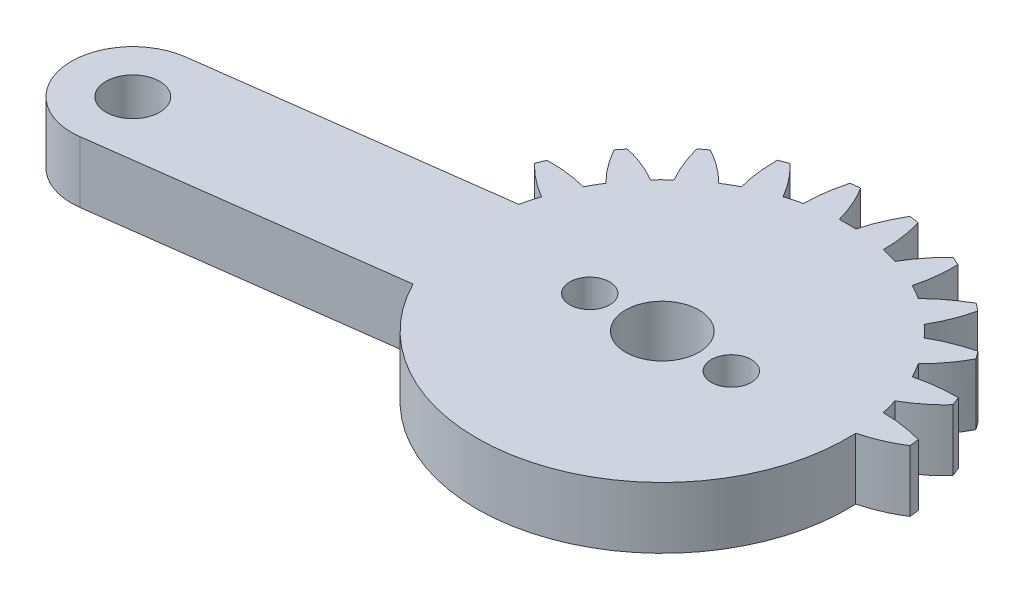
from build123d import *

# Parameters (mm, degrees)
CROQUIS1_R              = 2.3915
CROQUIS1_R_2            = 1.3
CROQUIS1_R_3            = 1.75
SALIENTE_EXTRUIR1_DEPTH = 4
SALIENTE_EXTRUIR2_DEPTH = 4
MATRIZC1_COUNT          = 2
MATRIZC1_ANGLE          = 15
MATRIZC2_COPY_1_DEPTH   = 4
MATRIZC2_COPY_2_DEPTH   = 4
MATRIZC3_COPY_1_DEPTH   = 4
MATRIZC3_COPY_2_DEPTH   = 4
MATRIZC3_COPY_3_DEPTH   = 4
MATRIZC4_COPY_1_DEPTH   = 4
MATRIZC4_COPY_2_DEPTH   = 4
MATRIZC4_COPY_3_DEPTH   = 4
MATRIZC4_COPY_4_DEPTH   = 4
MATRIZC5_COPY_1_DEPTH   = 4
MATRIZC5_COPY_2_DEPTH   = 4
MATRIZC5_COPY_3_DEPTH   = 4
MATRIZC5_COPY_4_DEPTH   = 4
MATRIZC5_COPY_5_DEPTH   = 4
MATRIZC6_COPY_1_DEPTH   = 4
MATRIZC6_COPY_2_DEPTH   = 4
MATRIZC6_COPY_3_DEPTH   = 4
MATRIZC6_COPY_4_DEPTH   = 4
MATRIZC6_COPY_5_DEPTH   = 4
MATRIZC6_COPY_6_DEPTH   = 4
MATRIZC7_COPY_1_DEPTH   = 4
MATRIZC7_COPY_2_DEPTH   = 4
MATRIZC7_COPY_3_DEPTH   = 4
MATRIZC7_COPY_4_DEPTH   = 4
MATRIZC7_COPY_5_DEPTH   = 4
MATRIZC7_COPY_6_DEPTH   = 4
MATRIZC7_COPY_7_DEPTH   = 4
MATRIZC8_COPY_1_DEPTH   = 4
MATRIZC8_COPY_2_DEPTH   = 4
MATRIZC8_COPY_3_DEPTH   = 4
MATRIZC8_COPY_4_DEPTH   = 4
MATRIZC8_COPY_5_DEPTH   = 4
MATRIZC8_COPY_6_DEPTH   = 4
MATRIZC8_COPY_7_DEPTH   = 4
MATRIZC8_COPY_8_DEPTH   = 4
MATRIZC9_COPY_1_DEPTH   = 4
MATRIZC9_COPY_2_DEPTH   = 4
MATRIZC9_COPY_3_DEPTH   = 4
MATRIZC9_COPY_4_DEPTH   = 4
MATRIZC9_COPY_5_DEPTH   = 4
MATRIZC9_COPY_6_DEPTH   = 4
MATRIZC9_COPY_7_DEPTH   = 4
MATRIZC9_COPY_8_DEPTH   = 4
MATRIZC9_COPY_9_DEPTH   = 4
MATRIZC10_COPY_1_DEPTH  = 4
MATRIZC10_COPY_2_DEPTH  = 4
MATRIZC10_COPY_3_DEPTH  = 4
MATRIZC10_COPY_4_DEPTH  = 4
MATRIZC10_COPY_5_DEPTH  = 4
MATRIZC10_COPY_6_DEPTH  = 4
MATRIZC10_COPY_7_DEPTH  = 4
MATRIZC10_COPY_8_DEPTH  = 4
MATRIZC10_COPY_9_DEPTH  = 4
MATRIZC10_COPY_10_DEPTH = 4


with BuildPart() as part:
    # Croquis1 → Saliente-Extruir1 (new body)
    with BuildSketch(Plane(origin=(0, 0, 0), x_dir=(1, 0, 0), z_dir=(0, 1, 0))):
        with BuildLine():
            Line((-10.778067685, -5.465198737), (-29.956952078, -7.999839876))
            ThreePointArc((-29.956952078, -7.999839876), (-34.453235787, -4.553267385), (-31.006663296, -0.056983677))
            Line((-31.006663296, -0.056983677), (-11.827778902, 2.477657462))
            ThreePointArc((-11.827778902, 2.477657462), (11.980330385, 1.583295338), (-10.778067685, -5.465198737))
        make_face()
        Circle(CROQUIS1_R, mode=Mode.SUBTRACT)
        with Locations((4.5, 0)):
            Circle(CROQUIS1_R_2, mode=Mode.SUBTRACT)
        with Locations((-4.494, -0.232301528)):
            Circle(CROQUIS1_R_2, mode=Mode.SUBTRACT)
        with Locations((-30.481807687, -4.028411777)):
            Circle(CROQUIS1_R_3, mode=Mode.SUBTRACT)
    extrude(amount=SALIENTE_EXTRUIR1_DEPTH)

    # Croquis2 → Saliente-Extruir2 (add)
    with BuildSketch(Plane(origin=(0, 0, 0), x_dir=(1, 0, 0), z_dir=(0, 1, 0))):
        with BuildLine():
            Line((-13.395904035, 5.876359313), (-13.644464088, 5.304001121))
            add(Edge.make_bspline(
                [(-11.519571955, 3.651657462), (-12.572280463, 4.239350994), (-13.644464088, 5.304001121)],
                knots=[0, 0, 0, 0.551059003, 0.551059003, 0.551059003], degree=2))
            add(Edge.make_bspline(
                [(-11.519571955, 3.651657462), (-11.202300794, 4.649704038), (-10.724126138, 5.570301502)],
                knots=[0, 0, 0, 0.773723424, 0.773723424, 0.773723424], degree=2))
            add(Edge.make_bspline(
                [(-10.724126138, 5.570301502), (-12.067942215, 5.934177007), (-13.395904035, 5.876359313)],
                knots=[0, 0, 0, 0.450010826, 0.450010826, 0.450010826], degree=2))
        make_face()
    saliente_extruir2 = extrude(amount=SALIENTE_EXTRUIR2_DEPTH)

    # MatrizC1: Saliente-Extruir2 ×2 about axis
    matrizc1_axis = Axis((0, 0, 0), (0, -1, 0))
    for i in range(1, MATRIZC1_COUNT):
        add(saliente_extruir2.rotate(matrizc1_axis, i * MATRIZC1_ANGLE / (MATRIZC1_COUNT - 1)))

    # MatrizC2 copy 1 sketch → MatrizC2 copy 1 (add)
    with BuildSketch(Plane(origin=(0, 0, 0), x_dir=(0.866025404, 0, 0.5), z_dir=(0, 1, 0))):
        with BuildLine():
            Line((-13.395904035, 5.876359313), (-13.644464088, 5.304001121))
            add(Edge.make_bspline(
                [(-11.519571955, 3.651657462), (-12.572280463, 4.239350994), (-13.644464088, 5.304001121)],
                knots=[0, 0, 0, 0.551059003, 0.551059003, 0.551059003], degree=2))
            add(Edge.make_bspline(
                [(-11.519571955, 3.651657462), (-11.202300794, 4.649704038), (-10.724126138, 5.570301502)],
                knots=[0, 0, 0, 0.773723424, 0.773723424, 0.773723424], degree=2))
            add(Edge.make_bspline(
                [(-10.724126138, 5.570301502), (-12.067942215, 5.934177007), (-13.395904035, 5.876359313)],
                knots=[0, 0, 0, 0.450010826, 0.450010826, 0.450010826], degree=2))
        make_face()
    extrude(amount=MATRIZC2_COPY_1_DEPTH)

    # MatrizC2 copy 2 sketch → MatrizC2 copy 2 (add)
    with BuildSketch(Plane(origin=(0, 0, 0), x_dir=(0.965925826, 0, 0.258819045), z_dir=(0, 1, 0))):
        with BuildLine():
            Line((-13.395904035, 5.876359313), (-13.644464088, 5.304001121))
            add(Edge.make_bspline(
                [(-11.519571955, 3.651657462), (-12.572280463, 4.239350994), (-13.644464088, 5.304001121)],
                knots=[0, 0, 0, 0.551059003, 0.551059003, 0.551059003], degree=2))
            add(Edge.make_bspline(
                [(-11.519571955, 3.651657462), (-11.202300794, 4.649704038), (-10.724126138, 5.570301502)],
                knots=[0, 0, 0, 0.773723424, 0.773723424, 0.773723424], degree=2))
            add(Edge.make_bspline(
                [(-10.724126138, 5.570301502), (-12.067942215, 5.934177007), (-13.395904035, 5.876359313)],
                knots=[0, 0, 0, 0.450010826, 0.450010826, 0.450010826], degree=2))
        make_face()
    extrude(amount=MATRIZC2_COPY_2_DEPTH)

    # MatrizC3 copy 1 sketch → MatrizC3 copy 1 (add)
    with BuildSketch(Plane(origin=(0, 0, 0), x_dir=(0.707106781, 0, 0.707106781), z_dir=(0, 1, 0))):
        with BuildLine():
            Line((-13.395904035, 5.876359313), (-13.644464088, 5.304001121))
            add(Edge.make_bspline(
                [(-11.519571955, 3.651657462), (-12.572280463, 4.239350994), (-13.644464088, 5.304001121)],
                knots=[0, 0, 0, 0.551059003, 0.551059003, 0.551059003], degree=2))
            add(Edge.make_bspline(
                [(-11.519571955, 3.651657462), (-11.202300794, 4.649704038), (-10.724126138, 5.570301502)],
                knots=[0, 0, 0, 0.773723424, 0.773723424, 0.773723424], degree=2))
            add(Edge.make_bspline(
                [(-10.724126138, 5.570301502), (-12.067942215, 5.934177007), (-13.395904035, 5.876359313)],
                knots=[0, 0, 0, 0.450010826, 0.450010826, 0.450010826], degree=2))
        make_face()
    extrude(amount=MATRIZC3_COPY_1_DEPTH)

    # MatrizC3 copy 2 sketch → MatrizC3 copy 2 (add)
    with BuildSketch(Plane(origin=(0, 0, 0), x_dir=(0.866025404, 0, 0.5), z_dir=(0, 1, 0))):
        with BuildLine():
            Line((-13.395904035, 5.876359313), (-13.644464088, 5.304001121))
            add(Edge.make_bspline(
                [(-11.519571955, 3.651657462), (-12.572280463, 4.239350994), (-13.644464088, 5.304001121)],
                knots=[0, 0, 0, 0.551059003, 0.551059003, 0.551059003], degree=2))
            add(Edge.make_bspline(
                [(-11.519571955, 3.651657462), (-11.202300794, 4.649704038), (-10.724126138, 5.570301502)],
                knots=[0, 0, 0, 0.773723424, 0.773723424, 0.773723424], degree=2))
            add(Edge.make_bspline(
                [(-10.724126138, 5.570301502), (-12.067942215, 5.934177007), (-13.395904035, 5.876359313)],
                knots=[0, 0, 0, 0.450010826, 0.450010826, 0.450010826], degree=2))
        make_face()
    extrude(amount=MATRIZC3_COPY_2_DEPTH)

    # MatrizC3 copy 3 sketch → MatrizC3 copy 3 (add)
    with BuildSketch(Plane(origin=(0, 0, 0), x_dir=(0.965925826, 0, 0.258819045), z_dir=(0, 1, 0))):
        with BuildLine():
            Line((-13.395904035, 5.876359313), (-13.644464088, 5.304001121))
            add(Edge.make_bspline(
                [(-11.519571955, 3.651657462), (-12.572280463, 4.239350994), (-13.644464088, 5.304001121)],
                knots=[0, 0, 0, 0.551059003, 0.551059003, 0.551059003], degree=2))
            add(Edge.make_bspline(
                [(-11.519571955, 3.651657462), (-11.202300794, 4.649704038), (-10.724126138, 5.570301502)],
                knots=[0, 0, 0, 0.773723424, 0.773723424, 0.773723424], degree=2))
            add(Edge.make_bspline(
                [(-10.724126138, 5.570301502), (-12.067942215, 5.934177007), (-13.395904035, 5.876359313)],
                knots=[0, 0, 0, 0.450010826, 0.450010826, 0.450010826], degree=2))
        make_face()
    extrude(amount=MATRIZC3_COPY_3_DEPTH)

    # MatrizC4 copy 1 sketch → MatrizC4 copy 1 (add)
    with BuildSketch(Plane(origin=(0, 0, 0), x_dir=(0.5, 0, 0.866025404), z_dir=(0, 1, 0))):
        with BuildLine():
            Line((-13.395904035, 5.876359313), (-13.644464088, 5.304001121))
            add(Edge.make_bspline(
                [(-11.519571955, 3.651657462), (-12.572280463, 4.239350994), (-13.644464088, 5.304001121)],
                knots=[0, 0, 0, 0.551059003, 0.551059003, 0.551059003], degree=2))
            add(Edge.make_bspline(
                [(-11.519571955, 3.651657462), (-11.202300794, 4.649704038), (-10.724126138, 5.570301502)],
                knots=[0, 0, 0, 0.773723424, 0.773723424, 0.773723424], degree=2))
            add(Edge.make_bspline(
                [(-10.724126138, 5.570301502), (-12.067942215, 5.934177007), (-13.395904035, 5.876359313)],
                knots=[0, 0, 0, 0.450010826, 0.450010826, 0.450010826], degree=2))
        make_face()
    extrude(amount=MATRIZC4_COPY_1_DEPTH)

    # MatrizC4 copy 2 sketch → MatrizC4 copy 2 (add)
    with BuildSketch(Plane(origin=(0, 0, 0), x_dir=(0.707106781, 0, 0.707106781), z_dir=(0, 1, 0))):
        with BuildLine():
            Line((-13.395904035, 5.876359313), (-13.644464088, 5.304001121))
            add(Edge.make_bspline(
                [(-11.519571955, 3.651657462), (-12.572280463, 4.239350994), (-13.644464088, 5.304001121)],
                knots=[0, 0, 0, 0.551059003, 0.551059003, 0.551059003], degree=2))
            add(Edge.make_bspline(
                [(-11.519571955, 3.651657462), (-11.202300794, 4.649704038), (-10.724126138, 5.570301502)],
                knots=[0, 0, 0, 0.773723424, 0.773723424, 0.773723424], degree=2))
            add(Edge.make_bspline(
                [(-10.724126138, 5.570301502), (-12.067942215, 5.934177007), (-13.395904035, 5.876359313)],
                knots=[0, 0, 0, 0.450010826, 0.450010826, 0.450010826], degree=2))
        make_face()
    extrude(amount=MATRIZC4_COPY_2_DEPTH)

    # MatrizC4 copy 3 sketch → MatrizC4 copy 3 (add)
    with BuildSketch(Plane(origin=(0, 0, 0), x_dir=(0.866025404, 0, 0.5), z_dir=(0, 1, 0))):
        with BuildLine():
            Line((-13.395904035, 5.876359313), (-13.644464088, 5.304001121))
            add(Edge.make_bspline(
                [(-11.519571955, 3.651657462), (-12.572280463, 4.239350994), (-13.644464088, 5.304001121)],
                knots=[0, 0, 0, 0.551059003, 0.551059003, 0.551059003], degree=2))
            add(Edge.make_bspline(
                [(-11.519571955, 3.651657462), (-11.202300794, 4.649704038), (-10.724126138, 5.570301502)],
                knots=[0, 0, 0, 0.773723424, 0.773723424, 0.773723424], degree=2))
            add(Edge.make_bspline(
                [(-10.724126138, 5.570301502), (-12.067942215, 5.934177007), (-13.395904035, 5.876359313)],
                knots=[0, 0, 0, 0.450010826, 0.450010826, 0.450010826], degree=2))
        make_face()
    extrude(amount=MATRIZC4_COPY_3_DEPTH)

    # MatrizC4 copy 4 sketch → MatrizC4 copy 4 (add)
    with BuildSketch(Plane(origin=(0, 0, 0), x_dir=(0.965925826, 0, 0.258819045), z_dir=(0, 1, 0))):
        with BuildLine():
            Line((-13.395904035, 5.876359313), (-13.644464088, 5.304001121))
            add(Edge.make_bspline(
                [(-11.519571955, 3.651657462), (-12.572280463, 4.239350994), (-13.644464088, 5.304001121)],
                knots=[0, 0, 0, 0.551059003, 0.551059003, 0.551059003], degree=2))
            add(Edge.make_bspline(
                [(-11.519571955, 3.651657462), (-11.202300794, 4.649704038), (-10.724126138, 5.570301502)],
                knots=[0, 0, 0, 0.773723424, 0.773723424, 0.773723424], degree=2))
            add(Edge.make_bspline(
                [(-10.724126138, 5.570301502), (-12.067942215, 5.934177007), (-13.395904035, 5.876359313)],
                knots=[0, 0, 0, 0.450010826, 0.450010826, 0.450010826], degree=2))
        make_face()
    extrude(amount=MATRIZC4_COPY_4_DEPTH)

    # MatrizC5 copy 1 sketch → MatrizC5 copy 1 (add)
    with BuildSketch(Plane(origin=(0, 0, 0), x_dir=(0.258819045, 0, 0.965925826), z_dir=(0, 1, 0))):
        with BuildLine():
            Line((-13.395904035, 5.876359313), (-13.644464088, 5.304001121))
            add(Edge.make_bspline(
                [(-11.519571955, 3.651657462), (-12.572280463, 4.239350994), (-13.644464088, 5.304001121)],
                knots=[0, 0, 0, 0.551059003, 0.551059003, 0.551059003], degree=2))
            add(Edge.make_bspline(
                [(-11.519571955, 3.651657462), (-11.202300794, 4.649704038), (-10.724126138, 5.570301502)],
                knots=[0, 0, 0, 0.773723424, 0.773723424, 0.773723424], degree=2))
            add(Edge.make_bspline(
                [(-10.724126138, 5.570301502), (-12.067942215, 5.934177007), (-13.395904035, 5.876359313)],
                knots=[0, 0, 0, 0.450010826, 0.450010826, 0.450010826], degree=2))
        make_face()
    extrude(amount=MATRIZC5_COPY_1_DEPTH)

    # MatrizC5 copy 2 sketch → MatrizC5 copy 2 (add)
    with BuildSketch(Plane(origin=(0, 0, 0), x_dir=(0.5, 0, 0.866025404), z_dir=(0, 1, 0))):
        with BuildLine():
            Line((-13.395904035, 5.876359313), (-13.644464088, 5.304001121))
            add(Edge.make_bspline(
                [(-11.519571955, 3.651657462), (-12.572280463, 4.239350994), (-13.644464088, 5.304001121)],
                knots=[0, 0, 0, 0.551059003, 0.551059003, 0.551059003], degree=2))
            add(Edge.make_bspline(
                [(-11.519571955, 3.651657462), (-11.202300794, 4.649704038), (-10.724126138, 5.570301502)],
                knots=[0, 0, 0, 0.773723424, 0.773723424, 0.773723424], degree=2))
            add(Edge.make_bspline(
                [(-10.724126138, 5.570301502), (-12.067942215, 5.934177007), (-13.395904035, 5.876359313)],
                knots=[0, 0, 0, 0.450010826, 0.450010826, 0.450010826], degree=2))
        make_face()
    extrude(amount=MATRIZC5_COPY_2_DEPTH)

    # MatrizC5 copy 3 sketch → MatrizC5 copy 3 (add)
    with BuildSketch(Plane(origin=(0, 0, 0), x_dir=(0.707106781, 0, 0.707106781), z_dir=(0, 1, 0))):
        with BuildLine():
            Line((-13.395904035, 5.876359313), (-13.644464088, 5.304001121))
            add(Edge.make_bspline(
                [(-11.519571955, 3.651657462), (-12.572280463, 4.239350994), (-13.644464088, 5.304001121)],
                knots=[0, 0, 0, 0.551059003, 0.551059003, 0.551059003], degree=2))
            add(Edge.make_bspline(
                [(-11.519571955, 3.651657462), (-11.202300794, 4.649704038), (-10.724126138, 5.570301502)],
                knots=[0, 0, 0, 0.773723424, 0.773723424, 0.773723424], degree=2))
            add(Edge.make_bspline(
                [(-10.724126138, 5.570301502), (-12.067942215, 5.934177007), (-13.395904035, 5.876359313)],
                knots=[0, 0, 0, 0.450010826, 0.450010826, 0.450010826], degree=2))
        make_face()
    extrude(amount=MATRIZC5_COPY_3_DEPTH)

    # MatrizC5 copy 4 sketch → MatrizC5 copy 4 (add)
    with BuildSketch(Plane(origin=(0, 0, 0), x_dir=(0.866025404, 0, 0.5), z_dir=(0, 1, 0))):
        with BuildLine():
            Line((-13.395904035, 5.876359313), (-13.644464088, 5.304001121))
            add(Edge.make_bspline(
                [(-11.519571955, 3.651657462), (-12.572280463, 4.239350994), (-13.644464088, 5.304001121)],
                knots=[0, 0, 0, 0.551059003, 0.551059003, 0.551059003], degree=2))
            add(Edge.make_bspline(
                [(-11.519571955, 3.651657462), (-11.202300794, 4.649704038), (-10.724126138, 5.570301502)],
                knots=[0, 0, 0, 0.773723424, 0.773723424, 0.773723424], degree=2))
            add(Edge.make_bspline(
                [(-10.724126138, 5.570301502), (-12.067942215, 5.934177007), (-13.395904035, 5.876359313)],
                knots=[0, 0, 0, 0.450010826, 0.450010826, 0.450010826], degree=2))
        make_face()
    extrude(amount=MATRIZC5_COPY_4_DEPTH)

    # MatrizC5 copy 5 sketch → MatrizC5 copy 5 (add)
    with BuildSketch(Plane(origin=(0, 0, 0), x_dir=(0.965925826, 0, 0.258819045), z_dir=(0, 1, 0))):
        with BuildLine():
            Line((-13.395904035, 5.876359313), (-13.644464088, 5.304001121))
            add(Edge.make_bspline(
                [(-11.519571955, 3.651657462), (-12.572280463, 4.239350994), (-13.644464088, 5.304001121)],
                knots=[0, 0, 0, 0.551059003, 0.551059003, 0.551059003], degree=2))
            add(Edge.make_bspline(
                [(-11.519571955, 3.651657462), (-11.202300794, 4.649704038), (-10.724126138, 5.570301502)],
                knots=[0, 0, 0, 0.773723424, 0.773723424, 0.773723424], degree=2))
            add(Edge.make_bspline(
                [(-10.724126138, 5.570301502), (-12.067942215, 5.934177007), (-13.395904035, 5.876359313)],
                knots=[0, 0, 0, 0.450010826, 0.450010826, 0.450010826], degree=2))
        make_face()
    extrude(amount=MATRIZC5_COPY_5_DEPTH)

    # MatrizC6 copy 1 sketch → MatrizC6 copy 1 (add)
    with BuildSketch(Plane.ZX):
        with BuildLine():
            Line((-13.395904035, 5.876359313), (-13.644464088, 5.304001121))
            add(Edge.make_bspline(
                [(-11.519571955, 3.651657462), (-12.572280463, 4.239350994), (-13.644464088, 5.304001121)],
                knots=[0, 0, 0, 0.551059003, 0.551059003, 0.551059003], degree=2))
            add(Edge.make_bspline(
                [(-11.519571955, 3.651657462), (-11.202300794, 4.649704038), (-10.724126138, 5.570301502)],
                knots=[0, 0, 0, 0.773723424, 0.773723424, 0.773723424], degree=2))
            add(Edge.make_bspline(
                [(-10.724126138, 5.570301502), (-12.067942215, 5.934177007), (-13.395904035, 5.876359313)],
                knots=[0, 0, 0, 0.450010826, 0.450010826, 0.450010826], degree=2))
        make_face()
    extrude(amount=MATRIZC6_COPY_1_DEPTH)

    # MatrizC6 copy 2 sketch → MatrizC6 copy 2 (add)
    with BuildSketch(Plane(origin=(0, 0, 0), x_dir=(0.258819045, 0, 0.965925826), z_dir=(0, 1, 0))):
        with BuildLine():
            Line((-13.395904035, 5.876359313), (-13.644464088, 5.304001121))
            add(Edge.make_bspline(
                [(-11.519571955, 3.651657462), (-12.572280463, 4.239350994), (-13.644464088, 5.304001121)],
                knots=[0, 0, 0, 0.551059003, 0.551059003, 0.551059003], degree=2))
            add(Edge.make_bspline(
                [(-11.519571955, 3.651657462), (-11.202300794, 4.649704038), (-10.724126138, 5.570301502)],
                knots=[0, 0, 0, 0.773723424, 0.773723424, 0.773723424], degree=2))
            add(Edge.make_bspline(
                [(-10.724126138, 5.570301502), (-12.067942215, 5.934177007), (-13.395904035, 5.876359313)],
                knots=[0, 0, 0, 0.450010826, 0.450010826, 0.450010826], degree=2))
        make_face()
    extrude(amount=MATRIZC6_COPY_2_DEPTH)

    # MatrizC6 copy 3 sketch → MatrizC6 copy 3 (add)
    with BuildSketch(Plane(origin=(0, 0, 0), x_dir=(0.5, 0, 0.866025404), z_dir=(0, 1, 0))):
        with BuildLine():
            Line((-13.395904035, 5.876359313), (-13.644464088, 5.304001121))
            add(Edge.make_bspline(
                [(-11.519571955, 3.651657462), (-12.572280463, 4.239350994), (-13.644464088, 5.304001121)],
                knots=[0, 0, 0, 0.551059003, 0.551059003, 0.551059003], degree=2))
            add(Edge.make_bspline(
                [(-11.519571955, 3.651657462), (-11.202300794, 4.649704038), (-10.724126138, 5.570301502)],
                knots=[0, 0, 0, 0.773723424, 0.773723424, 0.773723424], degree=2))
            add(Edge.make_bspline(
                [(-10.724126138, 5.570301502), (-12.067942215, 5.934177007), (-13.395904035, 5.876359313)],
                knots=[0, 0, 0, 0.450010826, 0.450010826, 0.450010826], degree=2))
        make_face()
    extrude(amount=MATRIZC6_COPY_3_DEPTH)

    # MatrizC6 copy 4 sketch → MatrizC6 copy 4 (add)
    with BuildSketch(Plane(origin=(0, 0, 0), x_dir=(0.707106781, 0, 0.707106781), z_dir=(0, 1, 0))):
        with BuildLine():
            Line((-13.395904035, 5.876359313), (-13.644464088, 5.304001121))
            add(Edge.make_bspline(
                [(-11.519571955, 3.651657462), (-12.572280463, 4.239350994), (-13.644464088, 5.304001121)],
                knots=[0, 0, 0, 0.551059003, 0.551059003, 0.551059003], degree=2))
            add(Edge.make_bspline(
                [(-11.519571955, 3.651657462), (-11.202300794, 4.649704038), (-10.724126138, 5.570301502)],
                knots=[0, 0, 0, 0.773723424, 0.773723424, 0.773723424], degree=2))
            add(Edge.make_bspline(
                [(-10.724126138, 5.570301502), (-12.067942215, 5.934177007), (-13.395904035, 5.876359313)],
                knots=[0, 0, 0, 0.450010826, 0.450010826, 0.450010826], degree=2))
        make_face()
    extrude(amount=MATRIZC6_COPY_4_DEPTH)

    # MatrizC6 copy 5 sketch → MatrizC6 copy 5 (add)
    with BuildSketch(Plane(origin=(0, 0, 0), x_dir=(0.866025404, 0, 0.5), z_dir=(0, 1, 0))):
        with BuildLine():
            Line((-13.395904035, 5.876359313), (-13.644464088, 5.304001121))
            add(Edge.make_bspline(
                [(-11.519571955, 3.651657462), (-12.572280463, 4.239350994), (-13.644464088, 5.304001121)],
                knots=[0, 0, 0, 0.551059003, 0.551059003, 0.551059003], degree=2))
            add(Edge.make_bspline(
                [(-11.519571955, 3.651657462), (-11.202300794, 4.649704038), (-10.724126138, 5.570301502)],
                knots=[0, 0, 0, 0.773723424, 0.773723424, 0.773723424], degree=2))
            add(Edge.make_bspline(
                [(-10.724126138, 5.570301502), (-12.067942215, 5.934177007), (-13.395904035, 5.876359313)],
                knots=[0, 0, 0, 0.450010826, 0.450010826, 0.450010826], degree=2))
        make_face()
    extrude(amount=MATRIZC6_COPY_5_DEPTH)

    # MatrizC6 copy 6 sketch → MatrizC6 copy 6 (add)
    with BuildSketch(Plane(origin=(0, 0, 0), x_dir=(0.965925826, 0, 0.258819045), z_dir=(0, 1, 0))):
        with BuildLine():
            Line((-13.395904035, 5.876359313), (-13.644464088, 5.304001121))
            add(Edge.make_bspline(
                [(-11.519571955, 3.651657462), (-12.572280463, 4.239350994), (-13.644464088, 5.304001121)],
                knots=[0, 0, 0, 0.551059003, 0.551059003, 0.551059003], degree=2))
            add(Edge.make_bspline(
                [(-11.519571955, 3.651657462), (-11.202300794, 4.649704038), (-10.724126138, 5.570301502)],
                knots=[0, 0, 0, 0.773723424, 0.773723424, 0.773723424], degree=2))
            add(Edge.make_bspline(
                [(-10.724126138, 5.570301502), (-12.067942215, 5.934177007), (-13.395904035, 5.876359313)],
                knots=[0, 0, 0, 0.450010826, 0.450010826, 0.450010826], degree=2))
        make_face()
    extrude(amount=MATRIZC6_COPY_6_DEPTH)

    # MatrizC7 copy 1 sketch → MatrizC7 copy 1 (add)
    with BuildSketch(Plane(origin=(0, 0, 0), x_dir=(-0.258819045, 0, 0.965925826), z_dir=(0, 1, 0))):
        with BuildLine():
            Line((-13.395904035, 5.876359313), (-13.644464088, 5.304001121))
            add(Edge.make_bspline(
                [(-11.519571955, 3.651657462), (-12.572280463, 4.239350994), (-13.644464088, 5.304001121)],
                knots=[0, 0, 0, 0.551059003, 0.551059003, 0.551059003], degree=2))
            add(Edge.make_bspline(
                [(-11.519571955, 3.651657462), (-11.202300794, 4.649704038), (-10.724126138, 5.570301502)],
                knots=[0, 0, 0, 0.773723424, 0.773723424, 0.773723424], degree=2))
            add(Edge.make_bspline(
                [(-10.724126138, 5.570301502), (-12.067942215, 5.934177007), (-13.395904035, 5.876359313)],
                knots=[0, 0, 0, 0.450010826, 0.450010826, 0.450010826], degree=2))
        make_face()
    extrude(amount=MATRIZC7_COPY_1_DEPTH)

    # MatrizC7 copy 2 sketch → MatrizC7 copy 2 (add)
    with BuildSketch(Plane.ZX):
        with BuildLine():
            Line((-13.395904035, 5.876359313), (-13.644464088, 5.304001121))
            add(Edge.make_bspline(
                [(-11.519571955, 3.651657462), (-12.572280463, 4.239350994), (-13.644464088, 5.304001121)],
                knots=[0, 0, 0, 0.551059003, 0.551059003, 0.551059003], degree=2))
            add(Edge.make_bspline(
                [(-11.519571955, 3.651657462), (-11.202300794, 4.649704038), (-10.724126138, 5.570301502)],
                knots=[0, 0, 0, 0.773723424, 0.773723424, 0.773723424], degree=2))
            add(Edge.make_bspline(
                [(-10.724126138, 5.570301502), (-12.067942215, 5.934177007), (-13.395904035, 5.876359313)],
                knots=[0, 0, 0, 0.450010826, 0.450010826, 0.450010826], degree=2))
        make_face()
    extrude(amount=MATRIZC7_COPY_2_DEPTH)

    # MatrizC7 copy 3 sketch → MatrizC7 copy 3 (add)
    with BuildSketch(Plane(origin=(0, 0, 0), x_dir=(0.258819045, 0, 0.965925826), z_dir=(0, 1, 0))):
        with BuildLine():
            Line((-13.395904035, 5.876359313), (-13.644464088, 5.304001121))
            add(Edge.make_bspline(
                [(-11.519571955, 3.651657462), (-12.572280463, 4.239350994), (-13.644464088, 5.304001121)],
                knots=[0, 0, 0, 0.551059003, 0.551059003, 0.551059003], degree=2))
            add(Edge.make_bspline(
                [(-11.519571955, 3.651657462), (-11.202300794, 4.649704038), (-10.724126138, 5.570301502)],
                knots=[0, 0, 0, 0.773723424, 0.773723424, 0.773723424], degree=2))
            add(Edge.make_bspline(
                [(-10.724126138, 5.570301502), (-12.067942215, 5.934177007), (-13.395904035, 5.876359313)],
                knots=[0, 0, 0, 0.450010826, 0.450010826, 0.450010826], degree=2))
        make_face()
    extrude(amount=MATRIZC7_COPY_3_DEPTH)

    # MatrizC7 copy 4 sketch → MatrizC7 copy 4 (add)
    with BuildSketch(Plane(origin=(0, 0, 0), x_dir=(0.5, 0, 0.866025404), z_dir=(0, 1, 0))):
        with BuildLine():
            Line((-13.395904035, 5.876359313), (-13.644464088, 5.304001121))
            add(Edge.make_bspline(
                [(-11.519571955, 3.651657462), (-12.572280463, 4.239350994), (-13.644464088, 5.304001121)],
                knots=[0, 0, 0, 0.551059003, 0.551059003, 0.551059003], degree=2))
            add(Edge.make_bspline(
                [(-11.519571955, 3.651657462), (-11.202300794, 4.649704038), (-10.724126138, 5.570301502)],
                knots=[0, 0, 0, 0.773723424, 0.773723424, 0.773723424], degree=2))
            add(Edge.make_bspline(
                [(-10.724126138, 5.570301502), (-12.067942215, 5.934177007), (-13.395904035, 5.876359313)],
                knots=[0, 0, 0, 0.450010826, 0.450010826, 0.450010826], degree=2))
        make_face()
    extrude(amount=MATRIZC7_COPY_4_DEPTH)

    # MatrizC7 copy 5 sketch → MatrizC7 copy 5 (add)
    with BuildSketch(Plane(origin=(0, 0, 0), x_dir=(0.707106781, 0, 0.707106781), z_dir=(0, 1, 0))):
        with BuildLine():
            Line((-13.395904035, 5.876359313), (-13.644464088, 5.304001121))
            add(Edge.make_bspline(
                [(-11.519571955, 3.651657462), (-12.572280463, 4.239350994), (-13.644464088, 5.304001121)],
                knots=[0, 0, 0, 0.551059003, 0.551059003, 0.551059003], degree=2))
            add(Edge.make_bspline(
                [(-11.519571955, 3.651657462), (-11.202300794, 4.649704038), (-10.724126138, 5.570301502)],
                knots=[0, 0, 0, 0.773723424, 0.773723424, 0.773723424], degree=2))
            add(Edge.make_bspline(
                [(-10.724126138, 5.570301502), (-12.067942215, 5.934177007), (-13.395904035, 5.876359313)],
                knots=[0, 0, 0, 0.450010826, 0.450010826, 0.450010826], degree=2))
        make_face()
    extrude(amount=MATRIZC7_COPY_5_DEPTH)

    # MatrizC7 copy 6 sketch → MatrizC7 copy 6 (add)
    with BuildSketch(Plane(origin=(0, 0, 0), x_dir=(0.866025404, 0, 0.5), z_dir=(0, 1, 0))):
        with BuildLine():
            Line((-13.395904035, 5.876359313), (-13.644464088, 5.304001121))
            add(Edge.make_bspline(
                [(-11.519571955, 3.651657462), (-12.572280463, 4.239350994), (-13.644464088, 5.304001121)],
                knots=[0, 0, 0, 0.551059003, 0.551059003, 0.551059003], degree=2))
            add(Edge.make_bspline(
                [(-11.519571955, 3.651657462), (-11.202300794, 4.649704038), (-10.724126138, 5.570301502)],
                knots=[0, 0, 0, 0.773723424, 0.773723424, 0.773723424], degree=2))
            add(Edge.make_bspline(
                [(-10.724126138, 5.570301502), (-12.067942215, 5.934177007), (-13.395904035, 5.876359313)],
                knots=[0, 0, 0, 0.450010826, 0.450010826, 0.450010826], degree=2))
        make_face()
    extrude(amount=MATRIZC7_COPY_6_DEPTH)

    # MatrizC7 copy 7 sketch → MatrizC7 copy 7 (add)
    with BuildSketch(Plane(origin=(0, 0, 0), x_dir=(0.965925826, 0, 0.258819045), z_dir=(0, 1, 0))):
        with BuildLine():
            Line((-13.395904035, 5.876359313), (-13.644464088, 5.304001121))
            add(Edge.make_bspline(
                [(-11.519571955, 3.651657462), (-12.572280463, 4.239350994), (-13.644464088, 5.304001121)],
                knots=[0, 0, 0, 0.551059003, 0.551059003, 0.551059003], degree=2))
            add(Edge.make_bspline(
                [(-11.519571955, 3.651657462), (-11.202300794, 4.649704038), (-10.724126138, 5.570301502)],
                knots=[0, 0, 0, 0.773723424, 0.773723424, 0.773723424], degree=2))
            add(Edge.make_bspline(
                [(-10.724126138, 5.570301502), (-12.067942215, 5.934177007), (-13.395904035, 5.876359313)],
                knots=[0, 0, 0, 0.450010826, 0.450010826, 0.450010826], degree=2))
        make_face()
    extrude(amount=MATRIZC7_COPY_7_DEPTH)

    # MatrizC8 copy 1 sketch → MatrizC8 copy 1 (add)
    with BuildSketch(Plane(origin=(0, 0, 0), x_dir=(-0.5, 0, 0.866025404), z_dir=(0, 1, 0))):
        with BuildLine():
            Line((-13.395904035, 5.876359313), (-13.644464088, 5.304001121))
            add(Edge.make_bspline(
                [(-11.519571955, 3.651657462), (-12.572280463, 4.239350994), (-13.644464088, 5.304001121)],
                knots=[0, 0, 0, 0.551059003, 0.551059003, 0.551059003], degree=2))
            add(Edge.make_bspline(
                [(-11.519571955, 3.651657462), (-11.202300794, 4.649704038), (-10.724126138, 5.570301502)],
                knots=[0, 0, 0, 0.773723424, 0.773723424, 0.773723424], degree=2))
            add(Edge.make_bspline(
                [(-10.724126138, 5.570301502), (-12.067942215, 5.934177007), (-13.395904035, 5.876359313)],
                knots=[0, 0, 0, 0.450010826, 0.450010826, 0.450010826], degree=2))
        make_face()
    extrude(amount=MATRIZC8_COPY_1_DEPTH)

    # MatrizC8 copy 2 sketch → MatrizC8 copy 2 (add)
    with BuildSketch(Plane(origin=(0, 0, 0), x_dir=(-0.258819045, 0, 0.965925826), z_dir=(0, 1, 0))):
        with BuildLine():
            Line((-13.395904035, 5.876359313), (-13.644464088, 5.304001121))
            add(Edge.make_bspline(
                [(-11.519571955, 3.651657462), (-12.572280463, 4.239350994), (-13.644464088, 5.304001121)],
                knots=[0, 0, 0, 0.551059003, 0.551059003, 0.551059003], degree=2))
            add(Edge.make_bspline(
                [(-11.519571955, 3.651657462), (-11.202300794, 4.649704038), (-10.724126138, 5.570301502)],
                knots=[0, 0, 0, 0.773723424, 0.773723424, 0.773723424], degree=2))
            add(Edge.make_bspline(
                [(-10.724126138, 5.570301502), (-12.067942215, 5.934177007), (-13.395904035, 5.876359313)],
                knots=[0, 0, 0, 0.450010826, 0.450010826, 0.450010826], degree=2))
        make_face()
    extrude(amount=MATRIZC8_COPY_2_DEPTH)

    # MatrizC8 copy 3 sketch → MatrizC8 copy 3 (add)
    with BuildSketch(Plane.ZX):
        with BuildLine():
            Line((-13.395904035, 5.876359313), (-13.644464088, 5.304001121))
            add(Edge.make_bspline(
                [(-11.519571955, 3.651657462), (-12.572280463, 4.239350994), (-13.644464088, 5.304001121)],
                knots=[0, 0, 0, 0.551059003, 0.551059003, 0.551059003], degree=2))
            add(Edge.make_bspline(
                [(-11.519571955, 3.651657462), (-11.202300794, 4.649704038), (-10.724126138, 5.570301502)],
                knots=[0, 0, 0, 0.773723424, 0.773723424, 0.773723424], degree=2))
            add(Edge.make_bspline(
                [(-10.724126138, 5.570301502), (-12.067942215, 5.934177007), (-13.395904035, 5.876359313)],
                knots=[0, 0, 0, 0.450010826, 0.450010826, 0.450010826], degree=2))
        make_face()
    extrude(amount=MATRIZC8_COPY_3_DEPTH)

    # MatrizC8 copy 4 sketch → MatrizC8 copy 4 (add)
    with BuildSketch(Plane(origin=(0, 0, 0), x_dir=(0.258819045, 0, 0.965925826), z_dir=(0, 1, 0))):
        with BuildLine():
            Line((-13.395904035, 5.876359313), (-13.644464088, 5.304001121))
            add(Edge.make_bspline(
                [(-11.519571955, 3.651657462), (-12.572280463, 4.239350994), (-13.644464088, 5.304001121)],
                knots=[0, 0, 0, 0.551059003, 0.551059003, 0.551059003], degree=2))
            add(Edge.make_bspline(
                [(-11.519571955, 3.651657462), (-11.202300794, 4.649704038), (-10.724126138, 5.570301502)],
                knots=[0, 0, 0, 0.773723424, 0.773723424, 0.773723424], degree=2))
            add(Edge.make_bspline(
                [(-10.724126138, 5.570301502), (-12.067942215, 5.934177007), (-13.395904035, 5.876359313)],
                knots=[0, 0, 0, 0.450010826, 0.450010826, 0.450010826], degree=2))
        make_face()
    extrude(amount=MATRIZC8_COPY_4_DEPTH)

    # MatrizC8 copy 5 sketch → MatrizC8 copy 5 (add)
    with BuildSketch(Plane(origin=(0, 0, 0), x_dir=(0.5, 0, 0.866025404), z_dir=(0, 1, 0))):
        with BuildLine():
            Line((-13.395904035, 5.876359313), (-13.644464088, 5.304001121))
            add(Edge.make_bspline(
                [(-11.519571955, 3.651657462), (-12.572280463, 4.239350994), (-13.644464088, 5.304001121)],
                knots=[0, 0, 0, 0.551059003, 0.551059003, 0.551059003], degree=2))
            add(Edge.make_bspline(
                [(-11.519571955, 3.651657462), (-11.202300794, 4.649704038), (-10.724126138, 5.570301502)],
                knots=[0, 0, 0, 0.773723424, 0.773723424, 0.773723424], degree=2))
            add(Edge.make_bspline(
                [(-10.724126138, 5.570301502), (-12.067942215, 5.934177007), (-13.395904035, 5.876359313)],
                knots=[0, 0, 0, 0.450010826, 0.450010826, 0.450010826], degree=2))
        make_face()
    extrude(amount=MATRIZC8_COPY_5_DEPTH)

    # MatrizC8 copy 6 sketch → MatrizC8 copy 6 (add)
    with BuildSketch(Plane(origin=(0, 0, 0), x_dir=(0.707106781, 0, 0.707106781), z_dir=(0, 1, 0))):
        with BuildLine():
            Line((-13.395904035, 5.876359313), (-13.644464088, 5.304001121))
            add(Edge.make_bspline(
                [(-11.519571955, 3.651657462), (-12.572280463, 4.239350994), (-13.644464088, 5.304001121)],
                knots=[0, 0, 0, 0.551059003, 0.551059003, 0.551059003], degree=2))
            add(Edge.make_bspline(
                [(-11.519571955, 3.651657462), (-11.202300794, 4.649704038), (-10.724126138, 5.570301502)],
                knots=[0, 0, 0, 0.773723424, 0.773723424, 0.773723424], degree=2))
            add(Edge.make_bspline(
                [(-10.724126138, 5.570301502), (-12.067942215, 5.934177007), (-13.395904035, 5.876359313)],
                knots=[0, 0, 0, 0.450010826, 0.450010826, 0.450010826], degree=2))
        make_face()
    extrude(amount=MATRIZC8_COPY_6_DEPTH)

    # MatrizC8 copy 7 sketch → MatrizC8 copy 7 (add)
    with BuildSketch(Plane(origin=(0, 0, 0), x_dir=(0.866025404, 0, 0.5), z_dir=(0, 1, 0))):
        with BuildLine():
            Line((-13.395904035, 5.876359313), (-13.644464088, 5.304001121))
            add(Edge.make_bspline(
                [(-11.519571955, 3.651657462), (-12.572280463, 4.239350994), (-13.644464088, 5.304001121)],
                knots=[0, 0, 0, 0.551059003, 0.551059003, 0.551059003], degree=2))
            add(Edge.make_bspline(
                [(-11.519571955, 3.651657462), (-11.202300794, 4.649704038), (-10.724126138, 5.570301502)],
                knots=[0, 0, 0, 0.773723424, 0.773723424, 0.773723424], degree=2))
            add(Edge.make_bspline(
                [(-10.724126138, 5.570301502), (-12.067942215, 5.934177007), (-13.395904035, 5.876359313)],
                knots=[0, 0, 0, 0.450010826, 0.450010826, 0.450010826], degree=2))
        make_face()
    extrude(amount=MATRIZC8_COPY_7_DEPTH)

    # MatrizC8 copy 8 sketch → MatrizC8 copy 8 (add)
    with BuildSketch(Plane(origin=(0, 0, 0), x_dir=(0.965925826, 0, 0.258819045), z_dir=(0, 1, 0))):
        with BuildLine():
            Line((-13.395904035, 5.876359313), (-13.644464088, 5.304001121))
            add(Edge.make_bspline(
                [(-11.519571955, 3.651657462), (-12.572280463, 4.239350994), (-13.644464088, 5.304001121)],
                knots=[0, 0, 0, 0.551059003, 0.551059003, 0.551059003], degree=2))
            add(Edge.make_bspline(
                [(-11.519571955, 3.651657462), (-11.202300794, 4.649704038), (-10.724126138, 5.570301502)],
                knots=[0, 0, 0, 0.773723424, 0.773723424, 0.773723424], degree=2))
            add(Edge.make_bspline(
                [(-10.724126138, 5.570301502), (-12.067942215, 5.934177007), (-13.395904035, 5.876359313)],
                knots=[0, 0, 0, 0.450010826, 0.450010826, 0.450010826], degree=2))
        make_face()
    extrude(amount=MATRIZC8_COPY_8_DEPTH)

    # MatrizC9 copy 1 sketch → MatrizC9 copy 1 (add)
    with BuildSketch(Plane(origin=(0, 0, 0), x_dir=(-0.707106781, 0, 0.707106781), z_dir=(0, 1, 0))):
        with BuildLine():
            Line((-13.395904035, 5.876359313), (-13.644464088, 5.304001121))
            add(Edge.make_bspline(
                [(-11.519571955, 3.651657462), (-12.572280463, 4.239350994), (-13.644464088, 5.304001121)],
                knots=[0, 0, 0, 0.551059003, 0.551059003, 0.551059003], degree=2))
            add(Edge.make_bspline(
                [(-11.519571955, 3.651657462), (-11.202300794, 4.649704038), (-10.724126138, 5.570301502)],
                knots=[0, 0, 0, 0.773723424, 0.773723424, 0.773723424], degree=2))
            add(Edge.make_bspline(
                [(-10.724126138, 5.570301502), (-12.067942215, 5.934177007), (-13.395904035, 5.876359313)],
                knots=[0, 0, 0, 0.450010826, 0.450010826, 0.450010826], degree=2))
        make_face()
    extrude(amount=MATRIZC9_COPY_1_DEPTH)

    # MatrizC9 copy 2 sketch → MatrizC9 copy 2 (add)
    with BuildSketch(Plane(origin=(0, 0, 0), x_dir=(-0.5, 0, 0.866025404), z_dir=(0, 1, 0))):
        with BuildLine():
            Line((-13.395904035, 5.876359313), (-13.644464088, 5.304001121))
            add(Edge.make_bspline(
                [(-11.519571955, 3.651657462), (-12.572280463, 4.239350994), (-13.644464088, 5.304001121)],
                knots=[0, 0, 0, 0.551059003, 0.551059003, 0.551059003], degree=2))
            add(Edge.make_bspline(
                [(-11.519571955, 3.651657462), (-11.202300794, 4.649704038), (-10.724126138, 5.570301502)],
                knots=[0, 0, 0, 0.773723424, 0.773723424, 0.773723424], degree=2))
            add(Edge.make_bspline(
                [(-10.724126138, 5.570301502), (-12.067942215, 5.934177007), (-13.395904035, 5.876359313)],
                knots=[0, 0, 0, 0.450010826, 0.450010826, 0.450010826], degree=2))
        make_face()
    extrude(amount=MATRIZC9_COPY_2_DEPTH)

    # MatrizC9 copy 3 sketch → MatrizC9 copy 3 (add)
    with BuildSketch(Plane(origin=(0, 0, 0), x_dir=(-0.258819045, 0, 0.965925826), z_dir=(0, 1, 0))):
        with BuildLine():
            Line((-13.395904035, 5.876359313), (-13.644464088, 5.304001121))
            add(Edge.make_bspline(
                [(-11.519571955, 3.651657462), (-12.572280463, 4.239350994), (-13.644464088, 5.304001121)],
                knots=[0, 0, 0, 0.551059003, 0.551059003, 0.551059003], degree=2))
            add(Edge.make_bspline(
                [(-11.519571955, 3.651657462), (-11.202300794, 4.649704038), (-10.724126138, 5.570301502)],
                knots=[0, 0, 0, 0.773723424, 0.773723424, 0.773723424], degree=2))
            add(Edge.make_bspline(
                [(-10.724126138, 5.570301502), (-12.067942215, 5.934177007), (-13.395904035, 5.876359313)],
                knots=[0, 0, 0, 0.450010826, 0.450010826, 0.450010826], degree=2))
        make_face()
    extrude(amount=MATRIZC9_COPY_3_DEPTH)

    # MatrizC9 copy 4 sketch → MatrizC9 copy 4 (add)
    with BuildSketch(Plane.ZX):
        with BuildLine():
            Line((-13.395904035, 5.876359313), (-13.644464088, 5.304001121))
            add(Edge.make_bspline(
                [(-11.519571955, 3.651657462), (-12.572280463, 4.239350994), (-13.644464088, 5.304001121)],
                knots=[0, 0, 0, 0.551059003, 0.551059003, 0.551059003], degree=2))
            add(Edge.make_bspline(
                [(-11.519571955, 3.651657462), (-11.202300794, 4.649704038), (-10.724126138, 5.570301502)],
                knots=[0, 0, 0, 0.773723424, 0.773723424, 0.773723424], degree=2))
            add(Edge.make_bspline(
                [(-10.724126138, 5.570301502), (-12.067942215, 5.934177007), (-13.395904035, 5.876359313)],
                knots=[0, 0, 0, 0.450010826, 0.450010826, 0.450010826], degree=2))
        make_face()
    extrude(amount=MATRIZC9_COPY_4_DEPTH)

    # MatrizC9 copy 5 sketch → MatrizC9 copy 5 (add)
    with BuildSketch(Plane(origin=(0, 0, 0), x_dir=(0.258819045, 0, 0.965925826), z_dir=(0, 1, 0))):
        with BuildLine():
            Line((-13.395904035, 5.876359313), (-13.644464088, 5.304001121))
            add(Edge.make_bspline(
                [(-11.519571955, 3.651657462), (-12.572280463, 4.239350994), (-13.644464088, 5.304001121)],
                knots=[0, 0, 0, 0.551059003, 0.551059003, 0.551059003], degree=2))
            add(Edge.make_bspline(
                [(-11.519571955, 3.651657462), (-11.202300794, 4.649704038), (-10.724126138, 5.570301502)],
                knots=[0, 0, 0, 0.773723424, 0.773723424, 0.773723424], degree=2))
            add(Edge.make_bspline(
                [(-10.724126138, 5.570301502), (-12.067942215, 5.934177007), (-13.395904035, 5.876359313)],
                knots=[0, 0, 0, 0.450010826, 0.450010826, 0.450010826], degree=2))
        make_face()
    extrude(amount=MATRIZC9_COPY_5_DEPTH)

    # MatrizC9 copy 6 sketch → MatrizC9 copy 6 (add)
    with BuildSketch(Plane(origin=(0, 0, 0), x_dir=(0.5, 0, 0.866025404), z_dir=(0, 1, 0))):
        with BuildLine():
            Line((-13.395904035, 5.876359313), (-13.644464088, 5.304001121))
            add(Edge.make_bspline(
                [(-11.519571955, 3.651657462), (-12.572280463, 4.239350994), (-13.644464088, 5.304001121)],
                knots=[0, 0, 0, 0.551059003, 0.551059003, 0.551059003], degree=2))
            add(Edge.make_bspline(
                [(-11.519571955, 3.651657462), (-11.202300794, 4.649704038), (-10.724126138, 5.570301502)],
                knots=[0, 0, 0, 0.773723424, 0.773723424, 0.773723424], degree=2))
            add(Edge.make_bspline(
                [(-10.724126138, 5.570301502), (-12.067942215, 5.934177007), (-13.395904035, 5.876359313)],
                knots=[0, 0, 0, 0.450010826, 0.450010826, 0.450010826], degree=2))
        make_face()
    extrude(amount=MATRIZC9_COPY_6_DEPTH)

    # MatrizC9 copy 7 sketch → MatrizC9 copy 7 (add)
    with BuildSketch(Plane(origin=(0, 0, 0), x_dir=(0.707106781, 0, 0.707106781), z_dir=(0, 1, 0))):
        with BuildLine():
            Line((-13.395904035, 5.876359313), (-13.644464088, 5.304001121))
            add(Edge.make_bspline(
                [(-11.519571955, 3.651657462), (-12.572280463, 4.239350994), (-13.644464088, 5.304001121)],
                knots=[0, 0, 0, 0.551059003, 0.551059003, 0.551059003], degree=2))
            add(Edge.make_bspline(
                [(-11.519571955, 3.651657462), (-11.202300794, 4.649704038), (-10.724126138, 5.570301502)],
                knots=[0, 0, 0, 0.773723424, 0.773723424, 0.773723424], degree=2))
            add(Edge.make_bspline(
                [(-10.724126138, 5.570301502), (-12.067942215, 5.934177007), (-13.395904035, 5.876359313)],
                knots=[0, 0, 0, 0.450010826, 0.450010826, 0.450010826], degree=2))
        make_face()
    extrude(amount=MATRIZC9_COPY_7_DEPTH)

    # MatrizC9 copy 8 sketch → MatrizC9 copy 8 (add)
    with BuildSketch(Plane(origin=(0, 0, 0), x_dir=(0.866025404, 0, 0.5), z_dir=(0, 1, 0))):
        with BuildLine():
            Line((-13.395904035, 5.876359313), (-13.644464088, 5.304001121))
            add(Edge.make_bspline(
                [(-11.519571955, 3.651657462), (-12.572280463, 4.239350994), (-13.644464088, 5.304001121)],
                knots=[0, 0, 0, 0.551059003, 0.551059003, 0.551059003], degree=2))
            add(Edge.make_bspline(
                [(-11.519571955, 3.651657462), (-11.202300794, 4.649704038), (-10.724126138, 5.570301502)],
                knots=[0, 0, 0, 0.773723424, 0.773723424, 0.773723424], degree=2))
            add(Edge.make_bspline(
                [(-10.724126138, 5.570301502), (-12.067942215, 5.934177007), (-13.395904035, 5.876359313)],
                knots=[0, 0, 0, 0.450010826, 0.450010826, 0.450010826], degree=2))
        make_face()
    extrude(amount=MATRIZC9_COPY_8_DEPTH)

    # MatrizC9 copy 9 sketch → MatrizC9 copy 9 (add)
    with BuildSketch(Plane(origin=(0, 0, 0), x_dir=(0.965925826, 0, 0.258819045), z_dir=(0, 1, 0))):
        with BuildLine():
            Line((-13.395904035, 5.876359313), (-13.644464088, 5.304001121))
            add(Edge.make_bspline(
                [(-11.519571955, 3.651657462), (-12.572280463, 4.239350994), (-13.644464088, 5.304001121)],
                knots=[0, 0, 0, 0.551059003, 0.551059003, 0.551059003], degree=2))
            add(Edge.make_bspline(
                [(-11.519571955, 3.651657462), (-11.202300794, 4.649704038), (-10.724126138, 5.570301502)],
                knots=[0, 0, 0, 0.773723424, 0.773723424, 0.773723424], degree=2))
            add(Edge.make_bspline(
                [(-10.724126138, 5.570301502), (-12.067942215, 5.934177007), (-13.395904035, 5.876359313)],
                knots=[0, 0, 0, 0.450010826, 0.450010826, 0.450010826], degree=2))
        make_face()
    extrude(amount=MATRIZC9_COPY_9_DEPTH)

    # MatrizC10 copy 1 sketch → MatrizC10 copy 1 (add)
    with BuildSketch(Plane(origin=(0, 0, 0), x_dir=(-0.866025404, 0, 0.5), z_dir=(0, 1, 0))):
        with BuildLine():
            Line((-13.395904035, 5.876359313), (-13.644464088, 5.304001121))
            add(Edge.make_bspline(
                [(-11.519571955, 3.651657462), (-12.572280463, 4.239350994), (-13.644464088, 5.304001121)],
                knots=[0, 0, 0, 0.551059003, 0.551059003, 0.551059003], degree=2))
            add(Edge.make_bspline(
                [(-11.519571955, 3.651657462), (-11.202300794, 4.649704038), (-10.724126138, 5.570301502)],
                knots=[0, 0, 0, 0.773723424, 0.773723424, 0.773723424], degree=2))
            add(Edge.make_bspline(
                [(-10.724126138, 5.570301502), (-12.067942215, 5.934177007), (-13.395904035, 5.876359313)],
                knots=[0, 0, 0, 0.450010826, 0.450010826, 0.450010826], degree=2))
        make_face()
    extrude(amount=MATRIZC10_COPY_1_DEPTH)

    # MatrizC10 copy 2 sketch → MatrizC10 copy 2 (add)
    with BuildSketch(Plane(origin=(0, 0, 0), x_dir=(-0.707106781, 0, 0.707106781), z_dir=(0, 1, 0))):
        with BuildLine():
            Line((-13.395904035, 5.876359313), (-13.644464088, 5.304001121))
            add(Edge.make_bspline(
                [(-11.519571955, 3.651657462), (-12.572280463, 4.239350994), (-13.644464088, 5.304001121)],
                knots=[0, 0, 0, 0.551059003, 0.551059003, 0.551059003], degree=2))
            add(Edge.make_bspline(
                [(-11.519571955, 3.651657462), (-11.202300794, 4.649704038), (-10.724126138, 5.570301502)],
                knots=[0, 0, 0, 0.773723424, 0.773723424, 0.773723424], degree=2))
            add(Edge.make_bspline(
                [(-10.724126138, 5.570301502), (-12.067942215, 5.934177007), (-13.395904035, 5.876359313)],
                knots=[0, 0, 0, 0.450010826, 0.450010826, 0.450010826], degree=2))
        make_face()
    extrude(amount=MATRIZC10_COPY_2_DEPTH)

    # MatrizC10 copy 3 sketch → MatrizC10 copy 3 (add)
    with BuildSketch(Plane(origin=(0, 0, 0), x_dir=(-0.5, 0, 0.866025404), z_dir=(0, 1, 0))):
        with BuildLine():
            Line((-13.395904035, 5.876359313), (-13.644464088, 5.304001121))
            add(Edge.make_bspline(
                [(-11.519571955, 3.651657462), (-12.572280463, 4.239350994), (-13.644464088, 5.304001121)],
                knots=[0, 0, 0, 0.551059003, 0.551059003, 0.551059003], degree=2))
            add(Edge.make_bspline(
                [(-11.519571955, 3.651657462), (-11.202300794, 4.649704038), (-10.724126138, 5.570301502)],
                knots=[0, 0, 0, 0.773723424, 0.773723424, 0.773723424], degree=2))
            add(Edge.make_bspline(
                [(-10.724126138, 5.570301502), (-12.067942215, 5.934177007), (-13.395904035, 5.876359313)],
                knots=[0, 0, 0, 0.450010826, 0.450010826, 0.450010826], degree=2))
        make_face()
    extrude(amount=MATRIZC10_COPY_3_DEPTH)

    # MatrizC10 copy 4 sketch → MatrizC10 copy 4 (add)
    with BuildSketch(Plane(origin=(0, 0, 0), x_dir=(-0.258819045, 0, 0.965925826), z_dir=(0, 1, 0))):
        with BuildLine():
            Line((-13.395904035, 5.876359313), (-13.644464088, 5.304001121))
            add(Edge.make_bspline(
                [(-11.519571955, 3.651657462), (-12.572280463, 4.239350994), (-13.644464088, 5.304001121)],
                knots=[0, 0, 0, 0.551059003, 0.551059003, 0.551059003], degree=2))
            add(Edge.make_bspline(
                [(-11.519571955, 3.651657462), (-11.202300794, 4.649704038), (-10.724126138, 5.570301502)],
                knots=[0, 0, 0, 0.773723424, 0.773723424, 0.773723424], degree=2))
            add(Edge.make_bspline(
                [(-10.724126138, 5.570301502), (-12.067942215, 5.934177007), (-13.395904035, 5.876359313)],
                knots=[0, 0, 0, 0.450010826, 0.450010826, 0.450010826], degree=2))
        make_face()
    extrude(amount=MATRIZC10_COPY_4_DEPTH)

    # MatrizC10 copy 5 sketch → MatrizC10 copy 5 (add)
    with BuildSketch(Plane.ZX):
        with BuildLine():
            Line((-13.395904035, 5.876359313), (-13.644464088, 5.304001121))
            add(Edge.make_bspline(
                [(-11.519571955, 3.651657462), (-12.572280463, 4.239350994), (-13.644464088, 5.304001121)],
                knots=[0, 0, 0, 0.551059003, 0.551059003, 0.551059003], degree=2))
            add(Edge.make_bspline(
                [(-11.519571955, 3.651657462), (-11.202300794, 4.649704038), (-10.724126138, 5.570301502)],
                knots=[0, 0, 0, 0.773723424, 0.773723424, 0.773723424], degree=2))
            add(Edge.make_bspline(
                [(-10.724126138, 5.570301502), (-12.067942215, 5.934177007), (-13.395904035, 5.876359313)],
                knots=[0, 0, 0, 0.450010826, 0.450010826, 0.450010826], degree=2))
        make_face()
    extrude(amount=MATRIZC10_COPY_5_DEPTH)

    # MatrizC10 copy 6 sketch → MatrizC10 copy 6 (add)
    with BuildSketch(Plane(origin=(0, 0, 0), x_dir=(0.258819045, 0, 0.965925826), z_dir=(0, 1, 0))):
        with BuildLine():
            Line((-13.395904035, 5.876359313), (-13.644464088, 5.304001121))
            add(Edge.make_bspline(
                [(-11.519571955, 3.651657462), (-12.572280463, 4.239350994), (-13.644464088, 5.304001121)],
                knots=[0, 0, 0, 0.551059003, 0.551059003, 0.551059003], degree=2))
            add(Edge.make_bspline(
                [(-11.519571955, 3.651657462), (-11.202300794, 4.649704038), (-10.724126138, 5.570301502)],
                knots=[0, 0, 0, 0.773723424, 0.773723424, 0.773723424], degree=2))
            add(Edge.make_bspline(
                [(-10.724126138, 5.570301502), (-12.067942215, 5.934177007), (-13.395904035, 5.876359313)],
                knots=[0, 0, 0, 0.450010826, 0.450010826, 0.450010826], degree=2))
        make_face()
    extrude(amount=MATRIZC10_COPY_6_DEPTH)

    # MatrizC10 copy 7 sketch → MatrizC10 copy 7 (add)
    with BuildSketch(Plane(origin=(0, 0, 0), x_dir=(0.5, 0, 0.866025404), z_dir=(0, 1, 0))):
        with BuildLine():
            Line((-13.395904035, 5.876359313), (-13.644464088, 5.304001121))
            add(Edge.make_bspline(
                [(-11.519571955, 3.651657462), (-12.572280463, 4.239350994), (-13.644464088, 5.304001121)],
                knots=[0, 0, 0, 0.551059003, 0.551059003, 0.551059003], degree=2))
            add(Edge.make_bspline(
                [(-11.519571955, 3.651657462), (-11.202300794, 4.649704038), (-10.724126138, 5.570301502)],
                knots=[0, 0, 0, 0.773723424, 0.773723424, 0.773723424], degree=2))
            add(Edge.make_bspline(
                [(-10.724126138, 5.570301502), (-12.067942215, 5.934177007), (-13.395904035, 5.876359313)],
                knots=[0, 0, 0, 0.450010826, 0.450010826, 0.450010826], degree=2))
        make_face()
    extrude(amount=MATRIZC10_COPY_7_DEPTH)

    # MatrizC10 copy 8 sketch → MatrizC10 copy 8 (add)
    with BuildSketch(Plane(origin=(0, 0, 0), x_dir=(0.707106781, 0, 0.707106781), z_dir=(0, 1, 0))):
        with BuildLine():
            Line((-13.395904035, 5.876359313), (-13.644464088, 5.304001121))
            add(Edge.make_bspline(
                [(-11.519571955, 3.651657462), (-12.572280463, 4.239350994), (-13.644464088, 5.304001121)],
                knots=[0, 0, 0, 0.551059003, 0.551059003, 0.551059003], degree=2))
            add(Edge.make_bspline(
                [(-11.519571955, 3.651657462), (-11.202300794, 4.649704038), (-10.724126138, 5.570301502)],
                knots=[0, 0, 0, 0.773723424, 0.773723424, 0.773723424], degree=2))
            add(Edge.make_bspline(
                [(-10.724126138, 5.570301502), (-12.067942215, 5.934177007), (-13.395904035, 5.876359313)],
                knots=[0, 0, 0, 0.450010826, 0.450010826, 0.450010826], degree=2))
        make_face()
    extrude(amount=MATRIZC10_COPY_8_DEPTH)

    # MatrizC10 copy 9 sketch → MatrizC10 copy 9 (add)
    with BuildSketch(Plane(origin=(0, 0, 0), x_dir=(0.866025404, 0, 0.5), z_dir=(0, 1, 0))):
        with BuildLine():
            Line((-13.395904035, 5.876359313), (-13.644464088, 5.304001121))
            add(Edge.make_bspline(
                [(-11.519571955, 3.651657462), (-12.572280463, 4.239350994), (-13.644464088, 5.304001121)],
                knots=[0, 0, 0, 0.551059003, 0.551059003, 0.551059003], degree=2))
            add(Edge.make_bspline(
                [(-11.519571955, 3.651657462), (-11.202300794, 4.649704038), (-10.724126138, 5.570301502)],
                knots=[0, 0, 0, 0.773723424, 0.773723424, 0.773723424], degree=2))
            add(Edge.make_bspline(
                [(-10.724126138, 5.570301502), (-12.067942215, 5.934177007), (-13.395904035, 5.876359313)],
                knots=[0, 0, 0, 0.450010826, 0.450010826, 0.450010826], degree=2))
        make_face()
    extrude(amount=MATRIZC10_COPY_9_DEPTH)

    # MatrizC10 copy 10 sketch → MatrizC10 copy 10 (add)
    with BuildSketch(Plane(origin=(0, 0, 0), x_dir=(0.965925826, 0, 0.258819045), z_dir=(0, 1, 0))):
        with BuildLine():
            Line((-13.395904035, 5.876359313), (-13.644464088, 5.304001121))
            add(Edge.make_bspline(
                [(-11.519571955, 3.651657462), (-12.572280463, 4.239350994), (-13.644464088, 5.304001121)],
                knots=[0, 0, 0, 0.551059003, 0.551059003, 0.551059003], degree=2))
            add(Edge.make_bspline(
                [(-11.519571955, 3.651657462), (-11.202300794, 4.649704038), (-10.724126138, 5.570301502)],
                knots=[0, 0, 0, 0.773723424, 0.773723424, 0.773723424], degree=2))
            add(Edge.make_bspline(
                [(-10.724126138, 5.570301502), (-12.067942215, 5.934177007), (-13.395904035, 5.876359313)],
                knots=[0, 0, 0, 0.450010826, 0.450010826, 0.450010826], degree=2))
        make_face()
    extrude(amount=MATRIZC10_COPY_10_DEPTH)


solid = part.part
